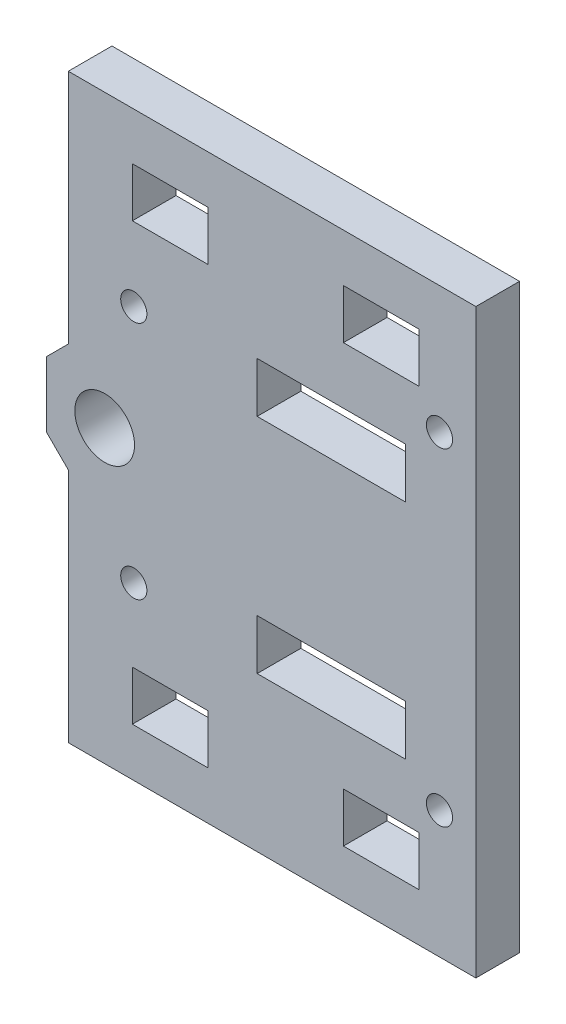
from build123d import *

# Parameters (mm, degrees)
MODEL_R                  = 1.8
MODEL_R_2                = 4.1
MODEL_W                  = 20.368459162
MODEL_H                  = 6.9
MODEL_W_2                = 10.4
MODEL_H_2                = 6.8
RESSALTO_EXTRUS_O1_DEPTH = 6


with BuildPart() as part:
    # Model → Ressalto-extrusão1 (new body)
    with BuildSketch(Plane.XY):
        Polygon((86.284167453, 87.365706057), (30.284167453, 87.365706057), (30.284167453, 54.904792152), (27.284167453, 51.904792152), (27.284167453, 42.926619963), (30.284167453, 39.926619963), (30.284167453, 7.465706057), (86.284167453, 7.465706057), align=None)
        with Locations((39.284167453, 30.965706057)):
            Circle(MODEL_R, mode=Mode.SUBTRACT)
        with Locations((81.284167453, 24.915706057)):
            Circle(MODEL_R, mode=Mode.SUBTRACT)
        with Locations((81.284167453, 69.915706057)):
            Circle(MODEL_R, mode=Mode.SUBTRACT)
        with Locations((39.284167453, 63.865706057)):
            Circle(MODEL_R, mode=Mode.SUBTRACT)
        with Locations((35.284167453, 47.415706057)):
            Circle(MODEL_R_2, mode=Mode.SUBTRACT)
        with Locations((66.417398963, 32.115706057)):
            Rectangle(MODEL_W, MODEL_H, mode=Mode.SUBTRACT)
        with Locations((44.284167453, 17.465706057)):
            Rectangle(MODEL_W_2, MODEL_H_2, mode=Mode.SUBTRACT)
        with Locations((44.284167453, 77.365706057)):
            Rectangle(MODEL_W_2, MODEL_H_2, mode=Mode.SUBTRACT)
        with Locations((66.417398963, 62.715706057)):
            Rectangle(MODEL_W, MODEL_H, mode=Mode.SUBTRACT)
        with Locations((73.284167453, 17.465706057)):
            Rectangle(MODEL_W_2, MODEL_H_2, mode=Mode.SUBTRACT)
        with Locations((73.284167453, 77.365706057)):
            Rectangle(MODEL_W_2, MODEL_H_2, mode=Mode.SUBTRACT)
    extrude(amount=RESSALTO_EXTRUS_O1_DEPTH)


solid = part.part
